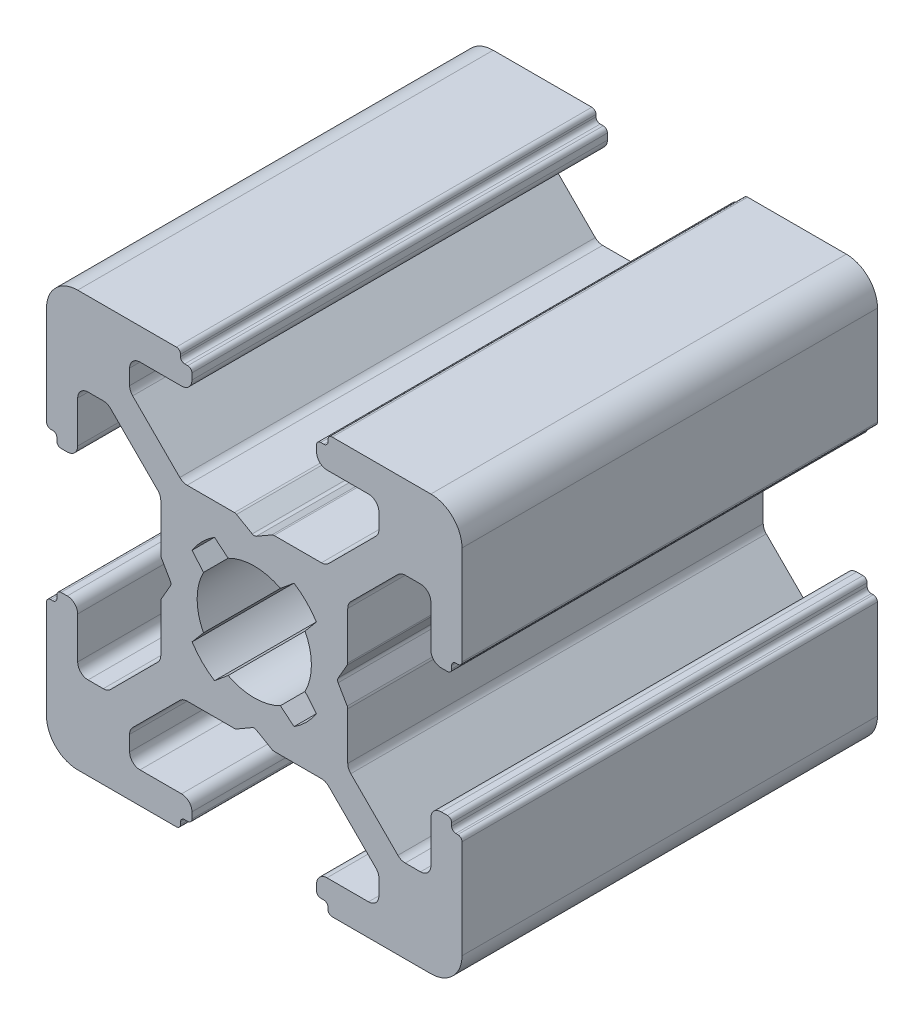
from build123d import *

# Parameters (mm, degrees)
DODANIE_WYCI_GNI_CIE1_DEPTH = 20


with BuildPart() as part:
    # Szkic1 → Dodanie-wyciągnięcie1 (new body)
    with BuildSketch(Plane.XY):
        with BuildLine():
            Line((6.249999773, 6.250000395), (1.5, 6.250000395))
            ThreePointArc((1.5, 6.250000395), (0.439339828, 5.810660567), (0, 4.750000395))
            Line((0, 4.750000395), (0, 0))
            ThreePointArc((0, 0), (0.058578644, -0.141421356), (0.2, -0.2))
            Line((0.2, -0.2), (0.300000268, -0.2))
            ThreePointArc((0.300000268, -0.2), (0.441421624, -0.258578644), (0.500000268, -0.4))
            Line((0.500000268, -0.4), (0.500000268, -0.549999605))
            ThreePointArc((0.500000268, -0.549999605), (0.558578912, -0.691420961), (0.700000268, -0.749999605))
            Line((0.700000268, -0.749999605), (1.000000268, -0.749999605))
            ThreePointArc((1.000000268, -0.749999605), (1.353553659, -0.603552995), (1.500000268, -0.249999605))
            Line((1.500000268, -0.249999605), (1.500000268, 1.75))
            ThreePointArc((1.500000268, 1.75), (1.646446877, 2.103553391), (2.000000268, 2.25))
            Line((2.000000268, 2.25), (2.732233315, 2.25))
            ThreePointArc((2.732233315, 2.25), (2.923575031, 2.211939766), (3.085786706, 2.103553391))
            Line((3.085786706, 2.103553391), (5.353553602, -0.164213506))
            ThreePointArc((5.353553602, -0.164213506), (5.461939977, -0.32642518), (5.500000211, -0.517766896))
            Line((5.500000211, -0.517766896), (5.500000211, -2.796410303))
            ThreePointArc((5.500000211, -2.796410303), (5.506815047, -2.848174114), (5.526795133, -2.896410307))
            Line((5.526795133, -2.896410307), (5.961880159, -3.649999636))
            ThreePointArc((5.961880159, -3.649999636), (5.988675071, -3.749999605), (5.961880159, -3.849999574))
            Line((5.961880159, -3.849999574), (5.526795133, -4.603588902))
            ThreePointArc((5.526795133, -4.603588902), (5.506815046, -4.651825095), (5.500000211, -4.703588906))
            Line((5.500000211, -4.703588906), (5.500000211, -6.982232313))
            ThreePointArc((5.500000211, -6.982232313), (5.461939977, -7.173574029), (5.353553602, -7.335785704))
            Line((5.353553602, -7.335785704), (3.085786706, -9.6035526))
            ThreePointArc((3.085786706, -9.6035526), (2.923575031, -9.711938976), (2.732233315, -9.749999209))
            Line((2.732233315, -9.749999209), (2.000000268, -9.749999209))
            ThreePointArc((2.000000268, -9.749999209), (1.646446877, -9.6035526), (1.500000268, -9.249999209))
            Line((1.500000268, -9.249999209), (1.500000268, -7.249999605))
            ThreePointArc((1.500000268, -7.249999605), (1.353553659, -6.896446214), (1.000000268, -6.749999605))
            Line((1.000000268, -6.749999605), (0.700000268, -6.749999605))
            ThreePointArc((0.700000268, -6.749999605), (0.558578912, -6.808578248), (0.500000268, -6.949999605))
            Line((0.500000268, -6.949999605), (0.500000268, -7.099999209))
            ThreePointArc((0.500000268, -7.099999209), (0.441421624, -7.241420566), (0.300000268, -7.299999209))
            Line((0.300000268, -7.299999209), (0.2, -7.299999209))
            ThreePointArc((0.2, -7.299999209), (0.058578644, -7.358577853), (0, -7.499999209))
            Line((0, -7.499999209), (0, -12.249999605))
            ThreePointArc((0, -12.249999605), (0.439339828, -13.310659776), (1.5, -13.749999605))
            Line((1.5, -13.749999605), (6.249999772, -13.749999605))
            ThreePointArc((6.249999772, -13.749999605), (6.391421129, -13.691420961), (6.449999772, -13.549999605))
            Line((6.449999772, -13.549999605), (6.449999772, -13.449999605))
            ThreePointArc((6.449999772, -13.449999605), (6.508578416, -13.308578248), (6.649999772, -13.249999605))
            Line((6.649999772, -13.249999605), (6.8, -13.249999605))
            ThreePointArc((6.8, -13.249999605), (6.941421356, -13.191420961), (7, -13.049999605))
            Line((7, -13.049999605), (7, -12.749999278))
            ThreePointArc((7, -12.749999278), (6.853553391, -12.396445888), (6.5, -12.249999278))
            Line((6.5, -12.249999278), (4.499999314, -12.249999278))
            ThreePointArc((4.499999314, -12.249999278), (4.146445923, -12.103552669), (3.999999314, -11.749999278))
            Line((3.999999314, -11.749999278), (3.999999314, -11.017766231))
            ThreePointArc((3.999999314, -11.017766231), (4.038059552, -10.826424504), (4.146445941, -10.664212823))
            Line((4.146445941, -10.664212823), (6.414212788, -8.396446197))
            ThreePointArc((6.414212788, -8.396446197), (6.576424456, -8.288059834), (6.767766161, -8.249999605))
            Line((6.767766161, -8.249999605), (9.046409688, -8.249999605))
            ThreePointArc((9.046409688, -8.249999605), (9.098173495, -8.243184771), (9.146409684, -8.223204688))
            Line((9.146409684, -8.223204688), (9.899999955, -7.788119166))
            ThreePointArc((9.899999955, -7.788119166), (10, -7.761324236), (10.100000045, -7.788119166))
            Line((10.100000045, -7.788119166), (10.853590316, -8.223204688))
            ThreePointArc((10.853590316, -8.223204688), (10.901826505, -8.243184771), (10.953590312, -8.249999605))
            Line((10.953590312, -8.249999605), (13.232233839, -8.249999605))
            ThreePointArc((13.232233839, -8.249999605), (13.423575544, -8.288059834), (13.585787212, -8.396446197))
            Line((13.585787212, -8.396446197), (15.853554059, -10.664212823))
            ThreePointArc((15.853554059, -10.664212823), (15.961940448, -10.826424504), (16.000000686, -11.017766231))
            Line((16.000000686, -11.017766231), (16.000000686, -11.749999278))
            ThreePointArc((16.000000686, -11.749999278), (15.853554077, -12.103552669), (15.500000686, -12.249999278))
            Line((15.500000686, -12.249999278), (13.5, -12.249999278))
            ThreePointArc((13.5, -12.249999278), (13.146446609, -12.396445888), (13, -12.749999278))
            Line((13, -12.749999278), (13, -13.049999605))
            ThreePointArc((13, -13.049999605), (13.058578644, -13.191420961), (13.2, -13.249999605))
            Line((13.2, -13.249999605), (13.350000227, -13.249999605))
            ThreePointArc((13.350000227, -13.249999605), (13.491421584, -13.308578248), (13.550000227, -13.449999605))
            Line((13.550000227, -13.449999605), (13.550000227, -13.549999605))
            ThreePointArc((13.550000227, -13.549999605), (13.608578871, -13.691420961), (13.750000227, -13.749999605))
            Line((13.750000227, -13.749999605), (18.5, -13.749999605))
            ThreePointArc((18.5, -13.749999605), (19.560660172, -13.310659776), (20, -12.249999605))
            Line((20, -12.249999605), (20, -7.499999209))
            ThreePointArc((20, -7.499999209), (19.941421356, -7.358577853), (19.8, -7.299999209))
            Line((19.8, -7.299999209), (19.699999732, -7.299999209))
            ThreePointArc((19.699999732, -7.299999209), (19.558578376, -7.241420566), (19.499999732, -7.099999209))
            Line((19.499999732, -7.099999209), (19.499999732, -6.949999605))
            ThreePointArc((19.499999732, -6.949999605), (19.441421088, -6.808578248), (19.299999732, -6.749999605))
            Line((19.299999732, -6.749999605), (18.999999732, -6.749999605))
            ThreePointArc((18.999999732, -6.749999605), (18.646446341, -6.896446214), (18.499999732, -7.249999605))
            Line((18.499999732, -7.249999605), (18.499999732, -9.249999209))
            ThreePointArc((18.499999732, -9.249999209), (18.353553123, -9.6035526), (17.999999732, -9.749999209))
            Line((17.999999732, -9.749999209), (17.267766685, -9.749999209))
            ThreePointArc((17.267766685, -9.749999209), (17.076424969, -9.711938976), (16.914213294, -9.6035526))
            Line((16.914213294, -9.6035526), (14.646446398, -7.335785704))
            ThreePointArc((14.646446398, -7.335785704), (14.538060023, -7.173574029), (14.499999789, -6.982232313))
            Line((14.499999789, -6.982232313), (14.499999789, -4.703588906))
            ThreePointArc((14.499999789, -4.703588906), (14.493184953, -4.651825095), (14.473204867, -4.603588902))
            Line((14.473204867, -4.603588902), (14.038119841, -3.849999574))
            ThreePointArc((14.038119841, -3.849999574), (14.011324929, -3.749999605), (14.038119841, -3.649999636))
            Line((14.038119841, -3.649999636), (14.473204867, -2.896410307))
            ThreePointArc((14.473204867, -2.896410307), (14.493184953, -2.848174114), (14.499999789, -2.796410303))
            Line((14.499999789, -2.796410303), (14.499999789, -0.517766896))
            ThreePointArc((14.499999789, -0.517766896), (14.538060023, -0.32642518), (14.646446398, -0.164213506))
            Line((14.646446398, -0.164213506), (16.914213294, 2.103553391))
            ThreePointArc((16.914213294, 2.103553391), (17.076424969, 2.211939766), (17.267766685, 2.25))
            Line((17.267766685, 2.25), (17.999999732, 2.25))
            ThreePointArc((17.999999732, 2.25), (18.353553123, 2.103553391), (18.499999732, 1.75))
            Line((18.499999732, 1.75), (18.499999732, -0.249999605))
            ThreePointArc((18.499999732, -0.249999605), (18.646446341, -0.603552995), (18.999999732, -0.749999605))
            Line((18.999999732, -0.749999605), (19.299999732, -0.749999605))
            ThreePointArc((19.299999732, -0.749999605), (19.441421088, -0.691420961), (19.499999732, -0.549999605))
            Line((19.499999732, -0.549999605), (19.499999732, -0.4))
            ThreePointArc((19.499999732, -0.4), (19.558578376, -0.258578644), (19.699999732, -0.2))
            Line((19.699999732, -0.2), (19.8, -0.2))
            ThreePointArc((19.8, -0.2), (19.941421356, -0.141421356), (20, 0))
            Line((20, 0), (20, 4.750000395))
            ThreePointArc((20, 4.750000395), (19.560660172, 5.810660567), (18.5, 6.250000395))
            Line((18.5, 6.250000395), (13.750000228, 6.250000395))
            ThreePointArc((13.750000228, 6.250000395), (13.608578871, 6.191421752), (13.550000228, 6.050000395))
            Line((13.550000228, 6.050000395), (13.550000228, 5.950000395))
            ThreePointArc((13.550000228, 5.950000395), (13.491421584, 5.808579039), (13.350000228, 5.750000395))
            Line((13.350000228, 5.750000395), (13.2, 5.750000395))
            ThreePointArc((13.2, 5.750000395), (13.058578644, 5.691421752), (13, 5.550000395))
            Line((13, 5.550000395), (13, 5.250000069))
            ThreePointArc((13, 5.250000069), (13.146446609, 4.896446678), (13.5, 4.750000069))
            Line((13.5, 4.750000069), (15.500000686, 4.750000069))
            ThreePointArc((15.500000686, 4.750000069), (15.853554077, 4.603553459), (16.000000686, 4.250000069))
            Line((16.000000686, 4.250000069), (16.000000686, 3.517767022))
            ThreePointArc((16.000000686, 3.517767022), (15.961940448, 3.326425294), (15.853554059, 3.164213614))
            Line((15.853554059, 3.164213614), (13.585787212, 0.896446988))
            ThreePointArc((13.585787212, 0.896446988), (13.423575544, 0.788060624), (13.232233839, 0.750000395))
            Line((13.232233839, 0.750000395), (10.953590312, 0.750000395))
            ThreePointArc((10.953590312, 0.750000395), (10.901826505, 0.743185561), (10.853590316, 0.723205479))
            Line((10.853590316, 0.723205479), (10.100000045, 0.288119957))
            ThreePointArc((10.100000045, 0.288119957), (10, 0.261325027), (9.899999955, 0.288119957))
            Line((9.899999955, 0.288119957), (9.146409684, 0.723205479))
            ThreePointArc((9.146409684, 0.723205479), (9.098173495, 0.743185561), (9.046409688, 0.750000395))
            Line((9.046409688, 0.750000395), (6.767766161, 0.750000395))
            ThreePointArc((6.767766161, 0.750000395), (6.576424456, 0.788060624), (6.414212788, 0.896446988))
            Line((6.414212788, 0.896446988), (4.146445941, 3.164213614))
            ThreePointArc((4.146445941, 3.164213614), (4.038059552, 3.326425294), (3.999999314, 3.517767022))
            Line((3.999999314, 3.517767022), (3.999999314, 4.250000069))
            ThreePointArc((3.999999314, 4.250000069), (4.146445923, 4.603553459), (4.499999314, 4.750000069))
            Line((4.499999314, 4.750000069), (6.5, 4.750000069))
            ThreePointArc((6.5, 4.750000069), (6.853553391, 4.896446678), (7, 5.250000069))
            Line((7, 5.250000069), (7, 5.550000395))
            ThreePointArc((7, 5.550000395), (6.941421356, 5.691421752), (6.8, 5.750000395))
            Line((6.8, 5.750000395), (6.649999772, 5.750000395))
            ThreePointArc((6.649999772, 5.750000395), (6.508578416, 5.808579039), (6.449999772, 5.950000395))
            Line((6.449999772, 5.950000395), (6.449999772, 6.050000395))
            ThreePointArc((6.449999772, 6.050000395), (6.391421129, 6.191421752), (6.249999773, 6.250000395))
        make_face()
        with BuildLine():
            Line((7.007825047, -1.840068643), (7.554704576, -2.491814288))
            ThreePointArc((7.554704576, -2.491814288), (7.25, -3.749999605), (7.554704576, -5.008184922))
            Line((7.554704576, -5.008184922), (7.007825046, -5.659930566))
            ThreePointArc((7.007825046, -5.659930566), (7.488262739, -6.25841009), (8.08610498, -6.739640567))
            Line((8.08610498, -6.739640567), (8.741814564, -6.195294967))
            ThreePointArc((8.741814564, -6.195294967), (10, -6.499999605), (11.258185436, -6.195294967))
            Line((11.258185436, -6.195294967), (11.913895019, -6.739640567))
            ThreePointArc((11.913895019, -6.739640567), (12.511737261, -6.25841009), (12.992174953, -5.659930566))
            Line((12.992174953, -5.659930566), (12.445295423, -5.008184922))
            ThreePointArc((12.445295423, -5.008184922), (12.75, -3.749999605), (12.445295423, -2.491814288))
            Line((12.445295423, -2.491814288), (12.992174953, -1.840068643))
            ThreePointArc((12.992174953, -1.840068643), (12.511737261, -1.241589119), (11.913895019, -0.760358642))
            Line((11.913895019, -0.760358642), (11.258185436, -1.304704243))
            ThreePointArc((11.258185436, -1.304704243), (10, -0.999999605), (8.741814564, -1.304704243))
            Line((8.741814564, -1.304704243), (8.08610498, -0.760358642))
            ThreePointArc((8.08610498, -0.760358642), (7.488262739, -1.241589119), (7.007825047, -1.840068643))
        make_face(mode=Mode.SUBTRACT)
    extrude(amount=DODANIE_WYCI_GNI_CIE1_DEPTH)


solid = part.part
